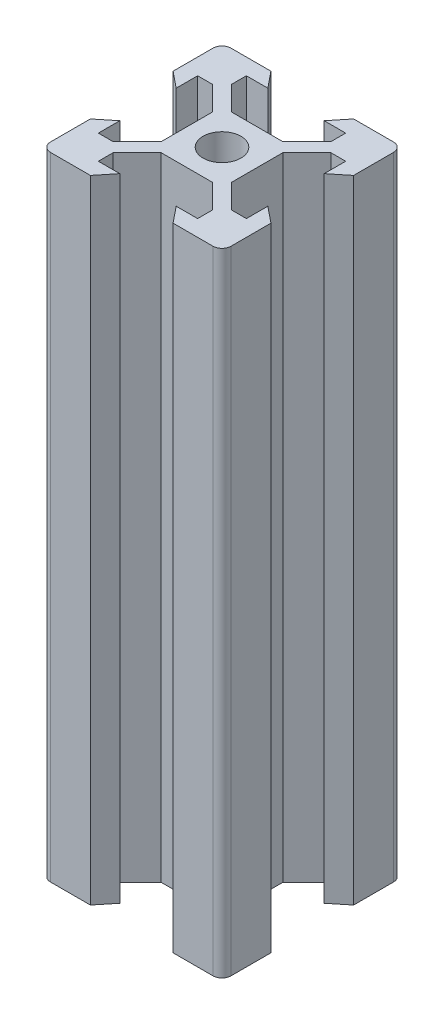
from build123d import *

# Parameters (mm, degrees)
SKETCH1_R           = 2.1
BOSS_EXTRUDE1_DEPTH = 70


with BuildPart() as part:
    # Sketch1 → Boss-Extrude1 (new body)
    with BuildSketch(Plane(origin=(0, 0, 0), x_dir=(1, 0, 0), z_dir=(0, 1, 0))):
        with BuildLine():
            Line((-5.5, 8.2), (-3.125, 8.2))
            Line((-3.125, 8.2), (-4.58, 10))
            Line((-4.58, 10), (-9, 10))
            ThreePointArc((-9, 10), (-9.707106781, 9.707106781), (-10, 9))
            Line((-10, 9), (-10, 4.58))
            Line((-10, 4.58), (-8.2, 3.125))
            Line((-8.2, 3.125), (-8.2, 5.5))
            Line((-8.2, 5.5), (-6.56, 5.5))
            Line((-6.56, 5.5), (-3.9, 2.84))
            Line((-3.9, 2.84), (-3.9, -2.84))
            Line((-3.9, -2.84), (-6.56, -5.5))
            Line((-6.56, -5.5), (-8.2, -5.5))
            Line((-8.2, -5.5), (-8.2, -3.125))
            Line((-8.2, -3.125), (-10, -4.58))
            Line((-10, -4.58), (-10, -9))
            ThreePointArc((-10, -9), (-9.707106781, -9.707106781), (-9, -10))
            Line((-9, -10), (-4.58, -10))
            Line((-4.58, -10), (-3.125, -8.2))
            Line((-3.125, -8.2), (-5.5, -8.2))
            Line((-5.5, -8.2), (-5.5, -6.56))
            Line((-5.5, -6.56), (-2.84, -3.9))
            Line((-2.84, -3.9), (2.84, -3.9))
            Line((2.84, -3.9), (5.5, -6.56))
            Line((5.5, -6.56), (5.5, -8.2))
            Line((5.5, -8.2), (3.125, -8.2))
            Line((3.125, -8.2), (4.58, -10))
            Line((4.58, -10), (9, -10))
            ThreePointArc((9, -10), (9.707106781, -9.707106781), (10, -9))
            Line((10, -9), (10, -4.58))
            Line((10, -4.58), (8.2, -3.125))
            Line((8.2, -3.125), (8.2, -5.5))
            Line((8.2, -5.5), (6.56, -5.5))
            Line((6.56, -5.5), (3.9, -2.84))
            Line((3.9, -2.84), (3.9, 2.84))
            Line((3.9, 2.84), (6.56, 5.5))
            Line((6.56, 5.5), (8.2, 5.5))
            Line((8.2, 5.5), (8.2, 3.125))
            Line((8.2, 3.125), (10, 4.58))
            Line((10, 4.58), (10, 9))
            ThreePointArc((10, 9), (9.707106781, 9.707106781), (9, 10))
            Line((9, 10), (4.58, 10))
            Line((4.58, 10), (3.125, 8.2))
            Line((3.125, 8.2), (5.5, 8.2))
            Line((5.5, 8.2), (5.5, 6.56))
            Line((5.5, 6.56), (2.84, 3.9))
            Line((2.84, 3.9), (-2.84, 3.9))
            Line((-2.84, 3.9), (-5.5, 6.56))
            Line((-5.5, 6.56), (-5.5, 8.2))
        make_face()
        Circle(SKETCH1_R, mode=Mode.SUBTRACT)
    extrude(amount=BOSS_EXTRUDE1_DEPTH)


solid = part.part
